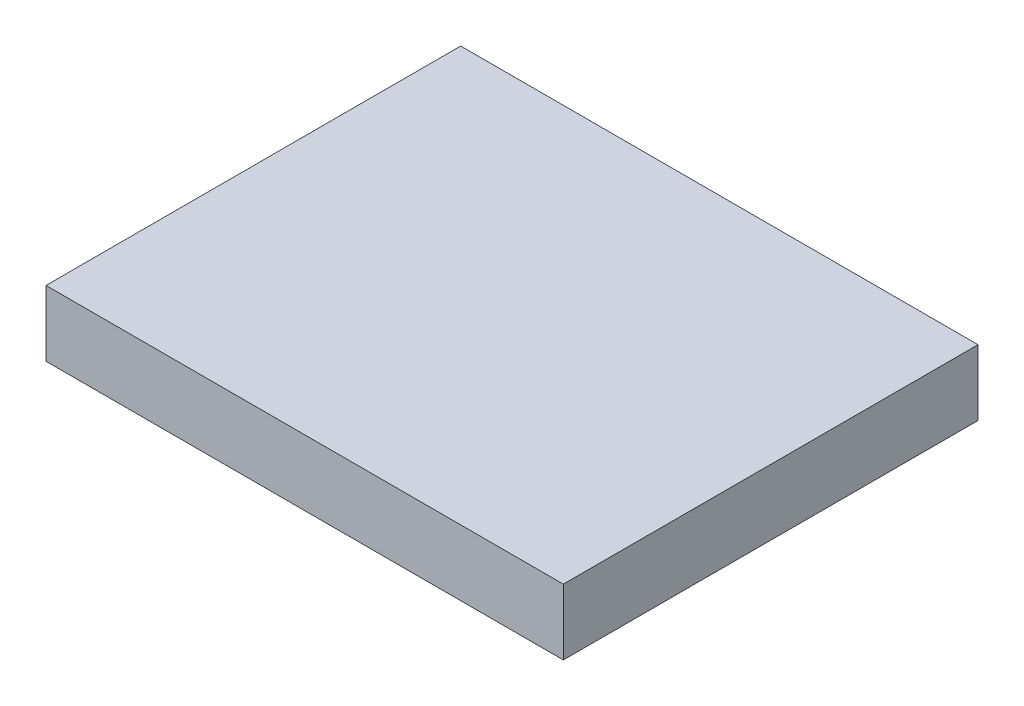
from build123d import *

# Parameters (mm, degrees)
SKETCH1_W           = 63
SKETCH1_H           = 50.5
BOSS_EXTRUDE1_DEPTH = 8


with BuildPart() as part:
    # Sketch1 → Boss-Extrude1 (new body)
    with BuildSketch(Plane(origin=(0, 0, 0), x_dir=(1, 0, 0), z_dir=(0, 1, 0))):
        Rectangle(SKETCH1_W, SKETCH1_H)
    extrude(amount=BOSS_EXTRUDE1_DEPTH)


solid = part.part
